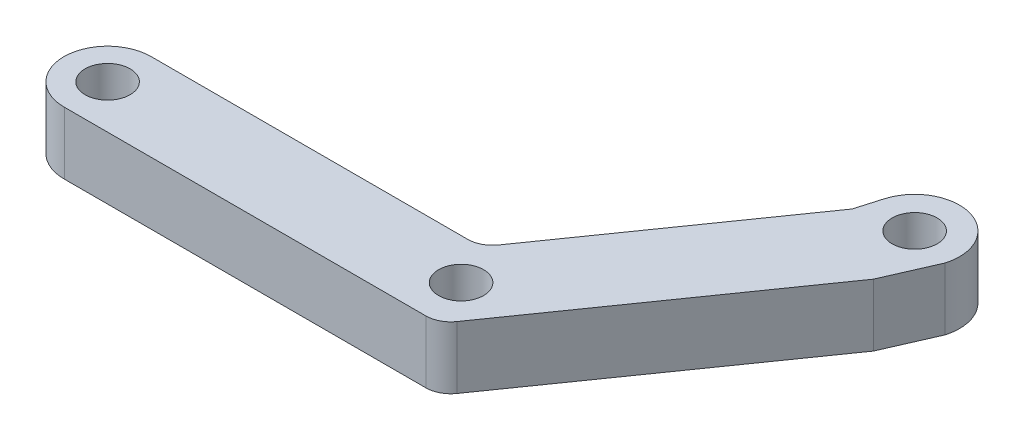
from build123d import *

# Parameters (mm, degrees)
SKETCH1_R           = 2.29235
BOSS_EXTRUDE1_DEPTH = 6.35


with BuildPart() as part:
    # Sketch1 → Boss-Extrude1 (new body)
    with BuildSketch(Plane(origin=(0, 0, 0), x_dir=(1, 0, 0), z_dir=(0, 1, 0))):
        with BuildLine():
            Line((0.048227533, 4.445), (32.250386453, 4.445))
            ThreePointArc((32.250386453, 4.445), (33.423227931, 4.731992484), (34.331032646, 5.528115852))
            Line((34.331032646, 5.528115852), (49.159221832, 26.704964681))
            Line((49.159221832, 26.704964681), (49.900908924, 29.244964681))
            ThreePointArc((49.900908924, 29.244964681), (55.562425443, 32.347386681), (58.664847444, 26.685870162))
            Line((58.664847444, 26.685870162), (56.441483505, 21.605870162))
            Line((56.441483505, 21.605870162), (38.958873725, -3.361884148))
            ThreePointArc((38.958873725, -3.361884148), (38.05106901, -4.158007516), (36.878227533, -4.445))
            Line((36.878227533, -4.445), (0.048227533, -4.445))
            ThreePointArc((0.048227533, -4.445), (-4.445261623, 0), (0.048227533, 4.445))
        make_face()
        Circle(SKETCH1_R, mode=Mode.SUBTRACT)
        with Locations((35.737148471, 0.286992484)):
            Circle(SKETCH1_R, mode=Mode.SUBTRACT)
        with Locations((54.282878184, 27.965417421)):
            Circle(SKETCH1_R, mode=Mode.SUBTRACT)
    extrude(amount=BOSS_EXTRUDE1_DEPTH)


solid = part.part
